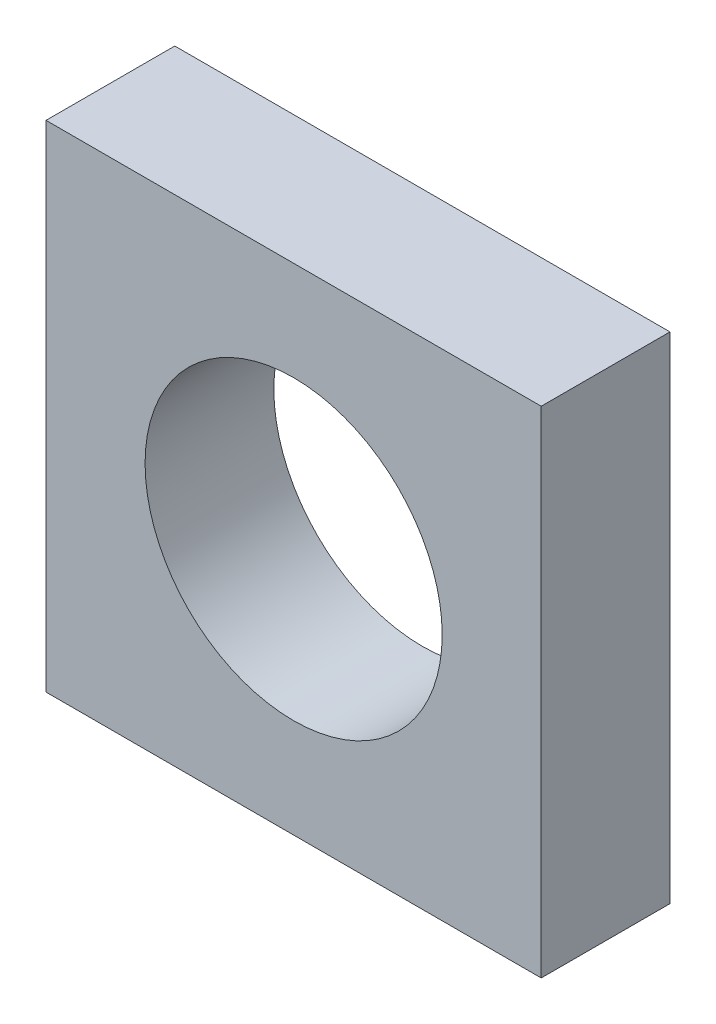
from build123d import *

# Parameters (mm, degrees)
SKETCH1_W           = 50
SKETCH1_H           = 50
SKETCH1_R           = 15
BOSS_EXTRUDE1_DEPTH = 13


with BuildPart() as part:
    # Sketch1 → Boss-Extrude1 (new body)
    with BuildSketch(Plane.XY):
        Rectangle(SKETCH1_W, SKETCH1_H)
        Circle(SKETCH1_R, mode=Mode.SUBTRACT)
    extrude(amount=BOSS_EXTRUDE1_DEPTH)


solid = part.part
